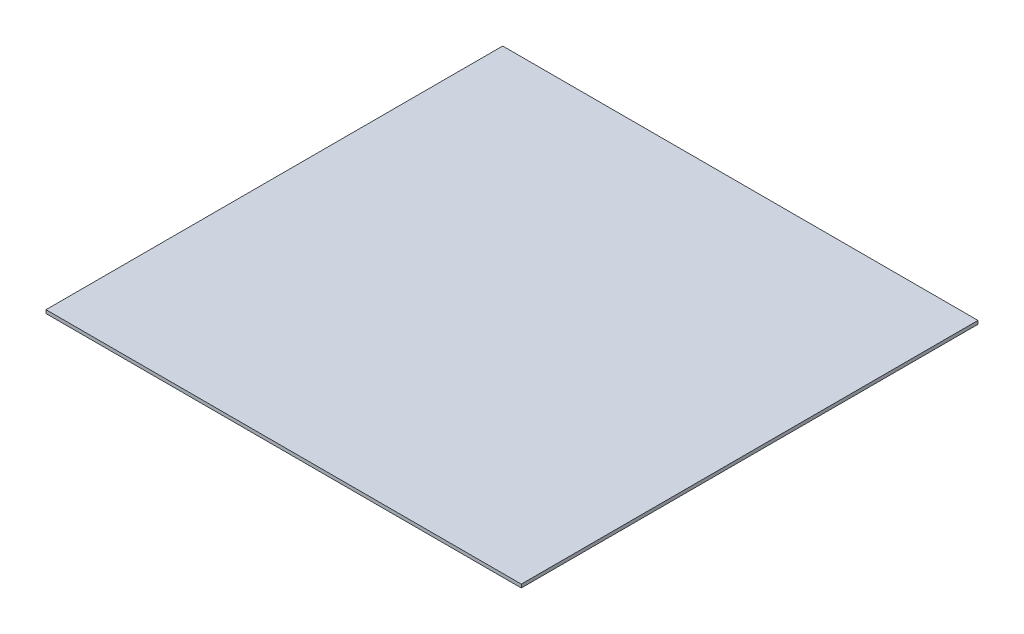
from build123d import *

# Parameters (mm, degrees)
SKETCH1_W           = 562
SKETCH1_H           = 540
BOSS_EXTRUDE1_DEPTH = 4


with BuildPart() as part:
    # Sketch1 → Boss-Extrude1 (new body)
    with BuildSketch(Plane(origin=(0, 0, 0), x_dir=(1, 0, 0), z_dir=(0, 1, 0))):
        Rectangle(SKETCH1_W, SKETCH1_H)
    extrude(amount=BOSS_EXTRUDE1_DEPTH)


solid = part.part
